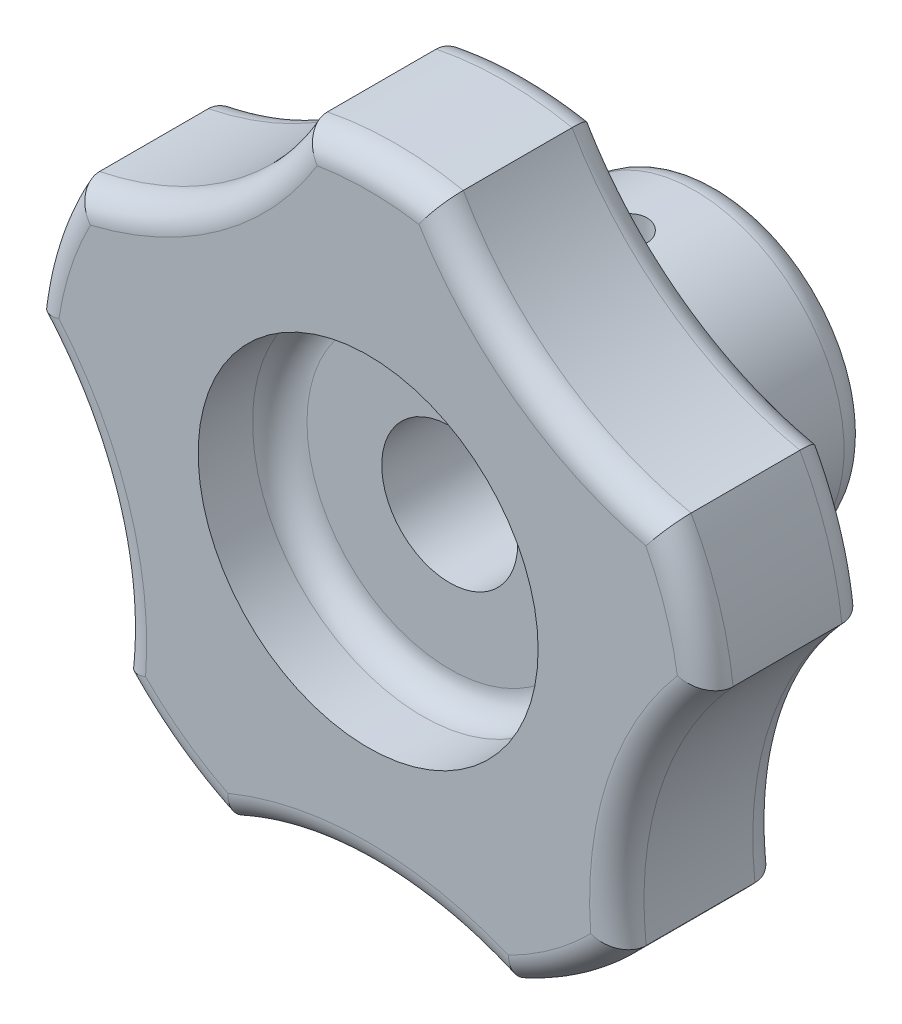
from build123d import *

# Parameters (mm, degrees)
CUT_EXTRUDE_1_REACH      = 28
SKETCH_3_R               = 1.5
CUT_EXTRUDE_2_DEPTH      = 26
CUT_EXTRUDE_2_DEPTH_BACK = 23.755714556
FILLET_1_R               = 2
CHAMFER_1_SIZE           = 1


with BuildPart() as part:
    # 草图1 → 旋转1 (revolve)
    with BuildSketch(Plane(origin=(0, 0, 0), x_dir=(1, 0, 0), z_dir=(0, 1, 0))):
        Polygon((5, 26), (11, 26), (11, 12), (25, 12), (25, 0), (12.5, 0), (12.5, 6), (5, 6), align=None)
    revolve(axis=Axis((0, 0, 0), (0, 0, -1)))

    # 草图2 → 切除-拉伸1 (cut, up to next)
    with BuildSketch(Plane.XY, mode=Mode.PRIVATE) as cut_extrude_1_sk1:
        with BuildLine():
            ThreePointArc((-21.750946843, 12.324622162), (-12.056315536, 16.594094731), (-5, 24.494897428))
            ThreePointArc((-5, 24.494897428), (-14.694631307, 20.225424859), (-21.750946843, 12.324622162))
        make_face()
    cut_extrude_1_tool1 = extrude(cut_extrude_1_sk1.sketch, amount=-CUT_EXTRUDE_1_REACH, mode=Mode.PRIVATE) & part.part
    add(cut_extrude_1_tool1.solids().sort_by_distance((-13.375473, 18.40976, 0))[0], mode=Mode.SUBTRACT)
    # 草图2 → 切除-拉伸1 (cut, up to next)
    with BuildSketch(Plane.XY, mode=Mode.PRIVATE) as cut_extrude_1_sk2:
        with BuildLine():
            ThreePointArc((-24.841116787, 2.814056999), (-23.776412907, -7.725424859), (-18.442824436, -16.877862033))
            ThreePointArc((-18.442824436, -16.877862033), (-19.507528316, -6.338380175), (-24.841116787, 2.814056999))
        make_face()
    cut_extrude_1_tool2 = extrude(cut_extrude_1_sk2.sketch, amount=-CUT_EXTRUDE_1_REACH, mode=Mode.PRIVATE) & part.part
    add(cut_extrude_1_tool2.solids().sort_by_distance((-21.641971, -7.031903, 0))[0], mode=Mode.SUBTRACT)
    # 草图2 → 切除-拉伸1 (cut, up to next)
    with BuildSketch(Plane.XY, mode=Mode.PRIVATE) as cut_extrude_1_sk3:
        with BuildLine():
            ThreePointArc((-10.352654493, -22.755714556), (0, -25), (10.352654493, -22.755714556))
            ThreePointArc((10.352654493, -22.755714556), (0, -20.511429112), (-10.352654493, -22.755714556))
        make_face()
    cut_extrude_1_tool3 = extrude(cut_extrude_1_sk3.sketch, amount=-CUT_EXTRUDE_1_REACH, mode=Mode.PRIVATE) & part.part
    add(cut_extrude_1_tool3.solids().sort_by_distance((0, -22.755715, 0))[0], mode=Mode.SUBTRACT)
    # 草图2 → 切除-拉伸1 (cut, up to next)
    with BuildSketch(Plane.XY, mode=Mode.PRIVATE) as cut_extrude_1_sk4:
        with BuildLine():
            ThreePointArc((18.442824436, -16.877862033), (23.303117934, -9.053435511), (25, 0))
            ThreePointArc((25, 0), (24.960247592, 1.409269374), (24.841116787, 2.814056999))
            ThreePointArc((24.841116787, 2.814056999), (19.507528316, -6.338380175), (18.442824436, -16.877862033))
        make_face()
    cut_extrude_1_tool4 = extrude(cut_extrude_1_sk4.sketch, amount=-CUT_EXTRUDE_1_REACH, mode=Mode.PRIVATE) & part.part
    add(cut_extrude_1_tool4.solids().sort_by_distance((21.641971, -7.031903, 0))[0], mode=Mode.SUBTRACT)
    # 草图2 → 切除-拉伸1 (cut, up to next)
    with BuildSketch(Plane.XY, mode=Mode.PRIVATE) as cut_extrude_1_sk5:
        with BuildLine():
            ThreePointArc((5, 24.494897428), (12.056315536, 16.594094731), (21.750946843, 12.324622162))
            ThreePointArc((21.750946843, 12.324622162), (14.694631307, 20.225424859), (5, 24.494897428))
        make_face()
    cut_extrude_1_tool5 = extrude(cut_extrude_1_sk5.sketch, amount=-CUT_EXTRUDE_1_REACH, mode=Mode.PRIVATE) & part.part
    add(cut_extrude_1_tool5.solids().sort_by_distance((13.375473, 18.40976, 0))[0], mode=Mode.SUBTRACT)

    # 草图3 → 切除-拉伸2 (cut, two sides)
    with BuildSketch(Plane(origin=(0, 0, 0), x_dir=(1, 0, 0), z_dir=(0, 1, 0))) as cut_extrude_2_sk:
        with Locations((0, 19)):
            Circle(SKETCH_3_R)
    extrude(amount=CUT_EXTRUDE_2_DEPTH, mode=Mode.SUBTRACT)
    extrude(cut_extrude_2_sk.sketch, amount=-CUT_EXTRUDE_2_DEPTH_BACK, mode=Mode.SUBTRACT)

    # 圆角1
    fillet_1_edges = [part.edges().sort_by_distance(p)[0] for p in [
        (0, 25, -12),
        (-23.776412907, 7.725424859, -12),
        (-14.694631307, -20.225424859, -12),
        (14.694631307, -20.225424859, -12),
        (0, 25, 0),
        (-23.776412907, 7.725424859, 0),
        (-14.694631307, -20.225424859, 0),
        (14.694631307, -20.225424859, 0),
        (-19.507528316, -6.338380175, -12),
        (-19.507528316, -6.338380175, 0),
        (0, -20.511429112, -12),
        (0, -20.511429112, 0),
        (19.507528316, -6.338380175, -12),
        (19.507528316, -6.338380175, 0),
        (12.056315536, 16.594094731, -12),
        (12.056315536, 16.594094731, 0),
        (-12.056315536, 16.594094731, -12),
        (-12.056315536, 16.594094731, 0),
        (-11, 0, -12),
        (23.776412907, 7.725424859, -12),
        (23.776412907, 7.725424859, 0),
        (-12.5, 0, -6),
        (-11, 0, -26),
    ]]
    fillet(fillet_1_edges, radius=FILLET_1_R)

    # 倒角1
    chamfer_1_edges = [part.edges().sort_by_distance(p)[0] for p in [
        (-5, 0, -26),
    ]]
    chamfer(chamfer_1_edges, length=CHAMFER_1_SIZE)


solid = part.part
